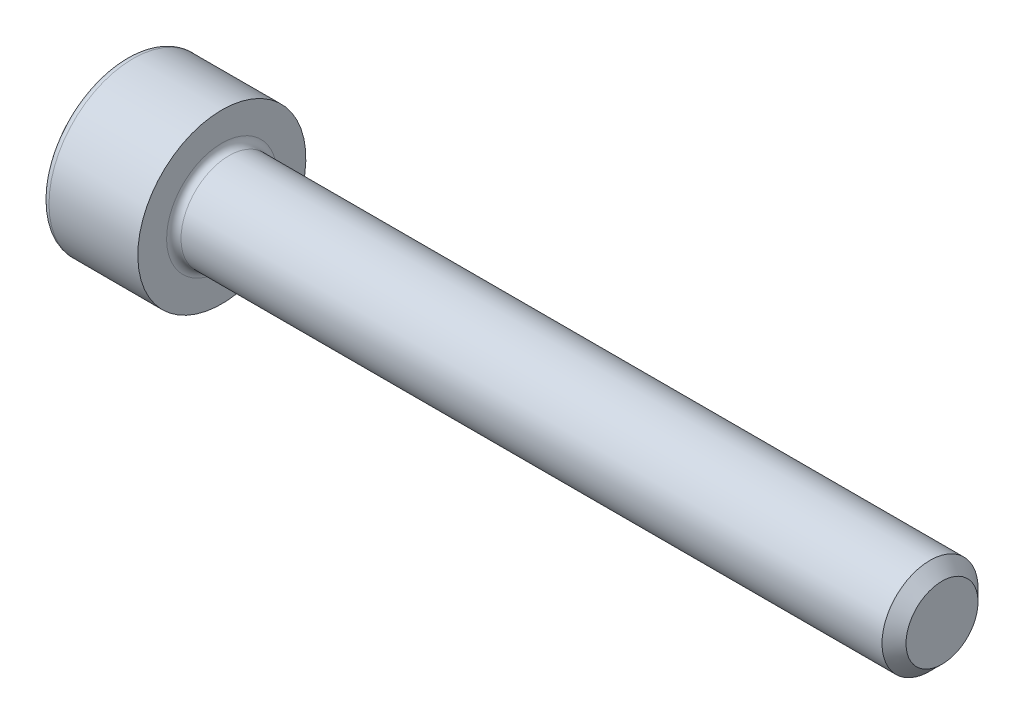
from build123d import *

# Parameters (mm, degrees)
CUT_EXTRUDE_1_DEPTH = 2.5
FILLET_1_R          = 0.3
CHAMFER_1_SIZE      = 0.5


with BuildPart() as part:
    # Эскиз1 → Повернуть1 (revolve)
    with BuildSketch(Plane.XY):
        Polygon((0, 0), (0, 3.5), (4, 3.5), (4, 2), (34, 2), (34, 0), align=None)
    revolve(axis=Axis((34, 0, 0), (-1, 0, 0)))

    # Эскиз2 → Вырез-Вытянуть1 (cut)
    with BuildSketch(Plane.ZY):
        Polygon((-1.154700538, 2), (-2.309401077, 0), (-1.154700538, -2), (1.154700538, -2), (2.309401077, 0), (1.154700538, 2), align=None)
    extrude(amount=-CUT_EXTRUDE_1_DEPTH, mode=Mode.SUBTRACT)

    # Скругление1
    fillet_1_edges = [part.edges().sort_by_distance(p)[0] for p in [
        (4, -2, 0),
        (0, -3.5, 0),
    ]]
    fillet(fillet_1_edges, radius=FILLET_1_R)

    # Фаска1
    chamfer_1_edges = [part.edges().sort_by_distance(p)[0] for p in [
        (34, -2, 0),
    ]]
    chamfer(chamfer_1_edges, length=CHAMFER_1_SIZE)


solid = part.part
